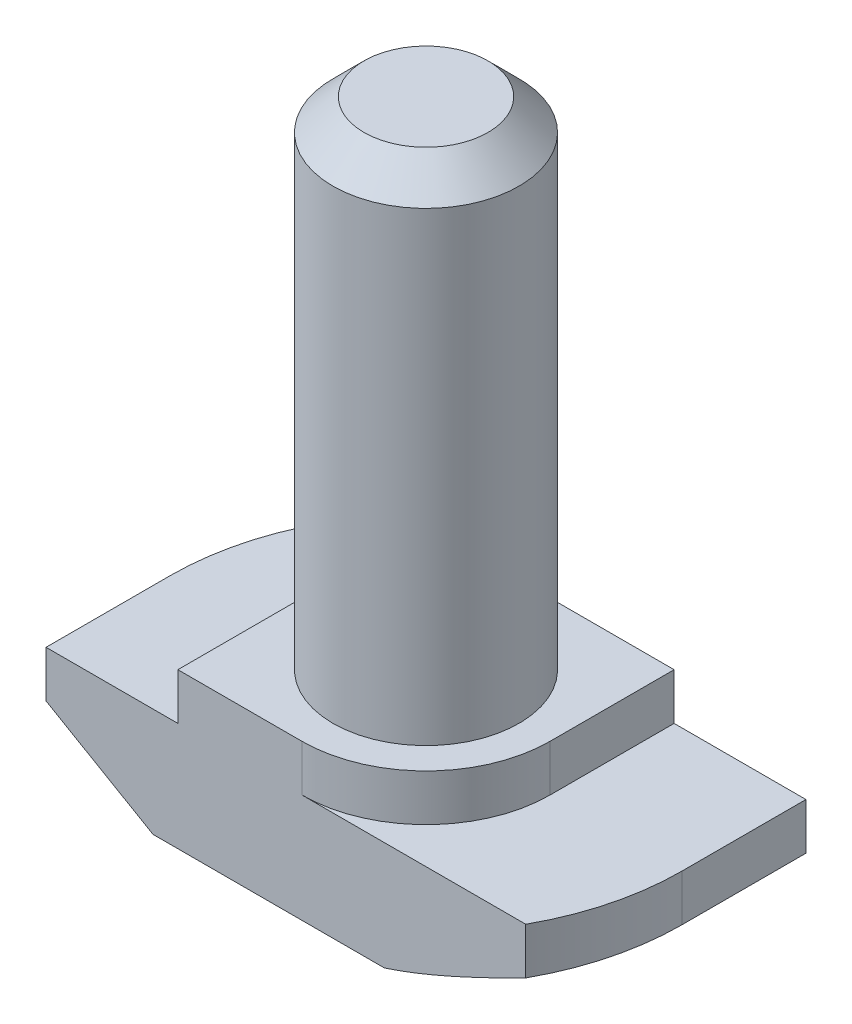
from build123d import *

# Parameters (mm, degrees)
EXTRUDE_1_DEPTH     = 4
SKETCH_2_R          = 3
EXTRUDE_2_DEPTH     = 16
CUT_EXTRUDE_1_DEPTH = 1.5
CUT_EXTRUDE_2_DEPTH = 4.5
CHAMFER_2_SIZE      = 1


with BuildPart() as part:
    # Эскиз1 → Бобышка-Вытянуть1 (new body, symmetric)
    with BuildSketch(Plane.XY):
        Polygon((8.25, 0), (-8.25, 0), (-8.25, 3.5), (-4, 3.5), (-4, 5), (4, 5), (4, 3.5), (8.25, 3.5), align=None)
    extrude(amount=EXTRUDE_1_DEPTH, both=True)

    # Эскиз2 → Бобышка-Вытянуть2 (add)
    with BuildSketch(Plane(origin=(0, 5, 0), x_dir=(1, 0, 0), z_dir=(0, 1, 0))):
        with Locations(Location((0, 0, 0), (0, 0, 270))):  # turned: the seam where the file's is
            Circle(SKETCH_2_R)
    extrude(amount=EXTRUDE_2_DEPTH)

    # Эскиз3 → Вырез-Вытянуть1 (cut)
    with BuildSketch(Plane(origin=(0, 5, 0), x_dir=(1, 0, 0), z_dir=(0, 1, 0))):
        with BuildLine():
            Line((-4, 0), (-4, 4))
            Line((-4, 4), (0, 4))
            ThreePointArc((0, 4), (-2.828427125, 2.828427125), (-4, 0))
        make_face()
        with BuildLine():
            Line((0, -4), (4, -4))
            Line((4, -4), (4, 0))
            ThreePointArc((4, 0), (2.828427125, -2.828427125), (0, -4))
        make_face()
    extrude(amount=-CUT_EXTRUDE_1_DEPTH, mode=Mode.SUBTRACT)

    # Эскиз4 → Вырез-Вытянуть2 (cut, through all)
    with BuildSketch(Plane(origin=(0, 3.5, 0), x_dir=(1, 0, 0), z_dir=(0, 1, 0))):
        with BuildLine():
            Line((-7.215434845, 4), (-8.25, 4))
            Line((-8.25, 4), (-8.25, 0))
            ThreePointArc((-8.25, 0), (-7.987172136, 2.065812495), (-7.215434845, 4))
        make_face()
        with BuildLine():
            Line((7.215434845, -4), (8.25, -4))
            Line((8.25, -4), (8.25, 0))
            ThreePointArc((8.25, 0), (7.987172136, -2.065812495), (7.215434845, -4))
        make_face()
    extrude(amount=-CUT_EXTRUDE_2_DEPTH, mode=Mode.SUBTRACT)

    # Вырез-По траектории1: sweep along a path in Эскиз6
    with BuildLine(Plane.XZ) as sweep_1_path:
        Line((0, -8.25), (8.25, -8.25))
        Line((8.25, -8.25), (8.25, 0))
        ThreePointArc((8.25, 0), (5.833630945, 5.833630945), (0, 8.25))
        Line((0, 8.25), (-8.25, 8.25))
        Line((-8.25, 8.25), (-8.25, 0))
        ThreePointArc((-8.25, 0), (-5.833630945, -5.833630945), (0, -8.25))
    # Эскиз5 → Вырез-По траектории1 (sweep, cut)
    with BuildSketch(Plane.XY.offset(4)):
        Polygon((-8.25, 2), (-4.8, 0), (-8.25, 0), align=None)
    sweep(path=sweep_1_path.line, transition=Transition.RIGHT, mode=Mode.SUBTRACT)

    # Фаска2
    chamfer_2_edges = [part.edges().sort_by_distance(p)[0] for p in [
        (0, 21, -3),
    ]]
    chamfer(chamfer_2_edges, length=CHAMFER_2_SIZE)


solid = part.part
